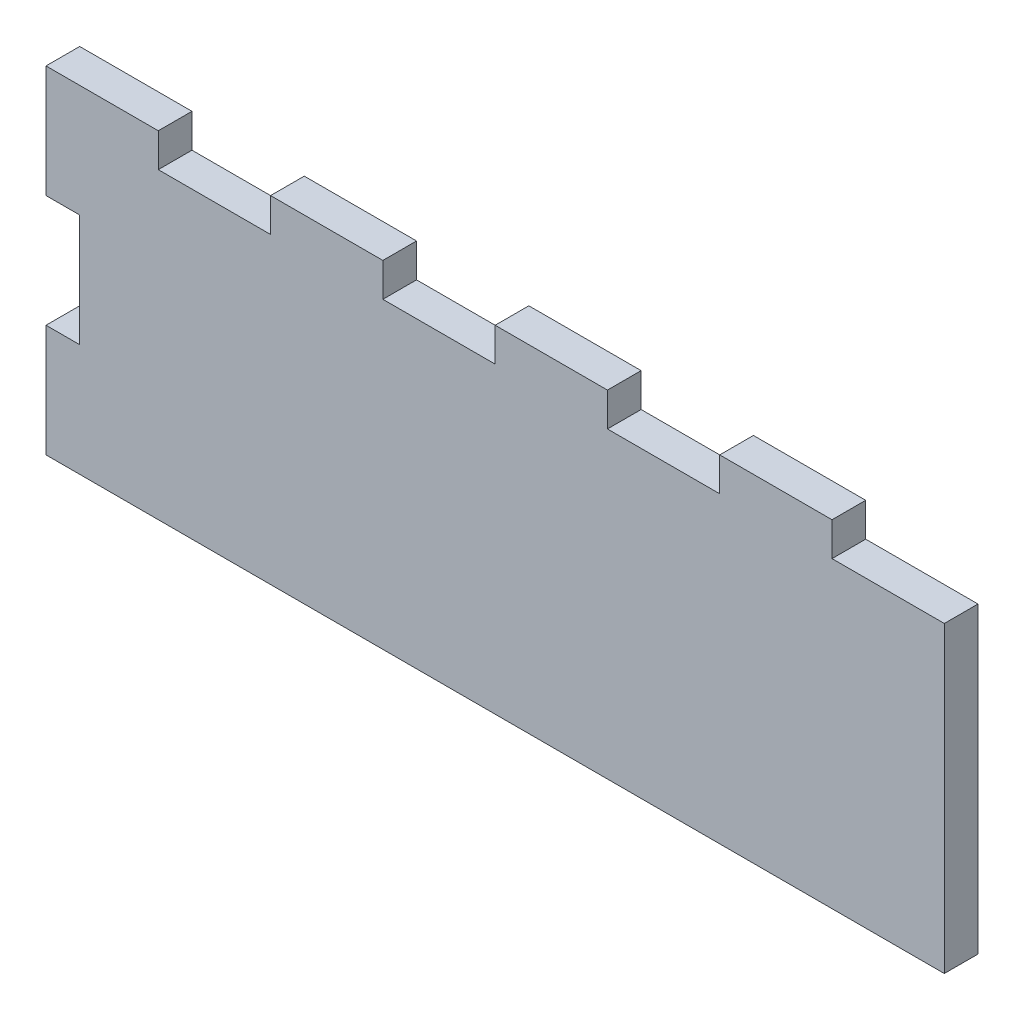
from build123d import *

# Parameters (mm, degrees)
ESQUISSE1_W                = 80
ESQUISSE1_H                = 30
BOSS_EXTRU_1_DEPTH         = 3
ESQUISSE2_W                = 10
ESQUISSE2_H                = 3
ENL_V_MAT_EXTRU_1_DEPTH    = 3
R_P_TITION_LIN_AIRE1_COUNT = 4
R_P_TITION_LIN_AIRE1_PITCH = 20
ESQUISSE3_W                = 3
ESQUISSE3_H                = 10
ENL_V_MAT_EXTRU_2_DEPTH    = 3


with BuildPart() as part:
    # Esquisse1 → Boss.-Extru.1 (new body)
    with BuildSketch(Plane.XY):
        with Locations((40, -15)):
            Rectangle(ESQUISSE1_W, ESQUISSE1_H)
    extrude(amount=BOSS_EXTRU_1_DEPTH)

    # Esquisse2 → Enlèv. mat.-Extru.1 (cut)
    with BuildSketch(Plane.XY.offset(3)):
        with Locations((75, -1.5)):
            Rectangle(ESQUISSE2_W, ESQUISSE2_H)
    enl_v_mat_extru_1 = extrude(amount=-ENL_V_MAT_EXTRU_1_DEPTH, mode=Mode.SUBTRACT)

    # Répétition linéaire1: Enlèv. mat.-Extru.1 ×4
    with Locations(*[(-i * R_P_TITION_LIN_AIRE1_PITCH, 0, 0) for i in range(1, R_P_TITION_LIN_AIRE1_COUNT)]):
        add(enl_v_mat_extru_1, mode=Mode.SUBTRACT)

    # Esquisse3 → Enlèv. mat.-Extru.2 (cut)
    with BuildSketch(Plane(origin=(0, 0, 0), x_dir=(-1, 0, 0), z_dir=(0, 0, -1))):
        with Locations((-1.5, -15)):
            Rectangle(ESQUISSE3_W, ESQUISSE3_H)
    extrude(amount=-ENL_V_MAT_EXTRU_2_DEPTH, mode=Mode.SUBTRACT)


solid = part.part
